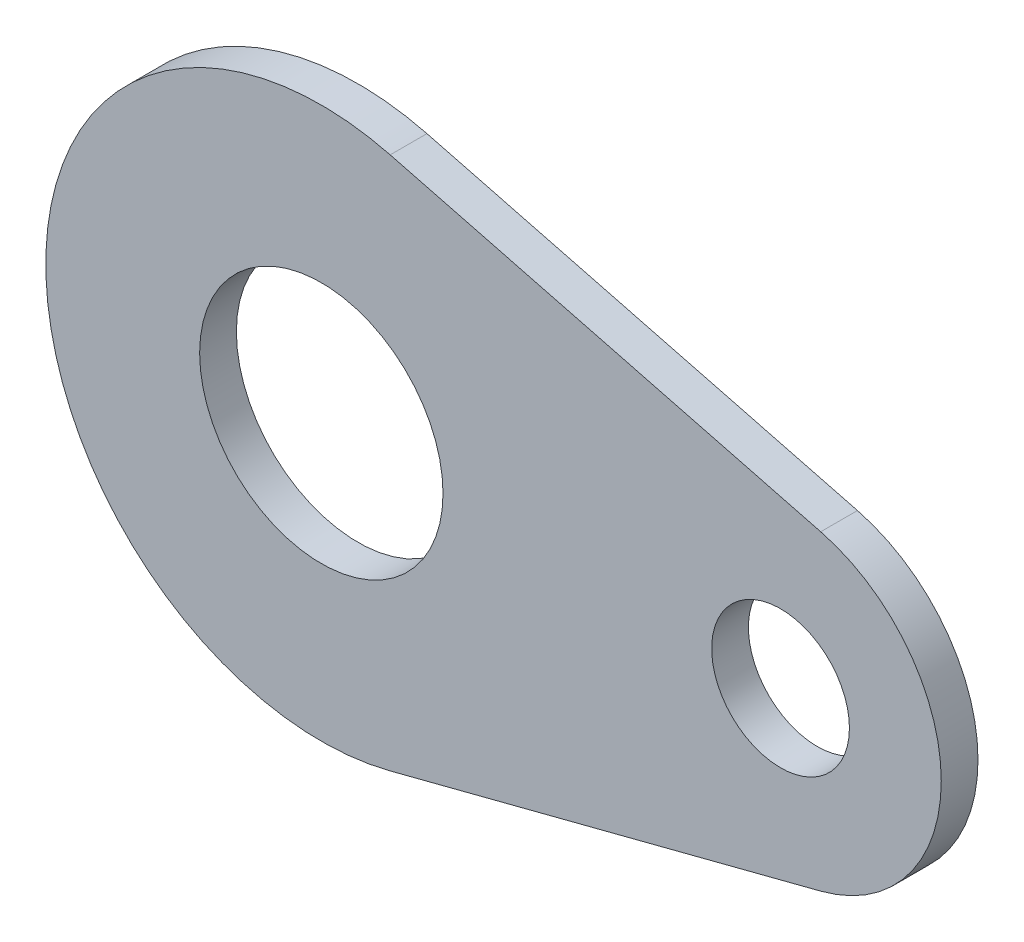
from build123d import *

# Parameters (mm, degrees)
SKETCH1_R           = 2.65
SKETCH1_R_2         = 1.5
BOSS_EXTRUDE1_DEPTH = 0.8


with BuildPart() as part:
    # Sketch1 → Boss-Extrude1 (new body)
    with BuildSketch(Plane.XY):
        with BuildLine():
            Line((1.5, 5.809475019), (10.875, 3.388860428))
            ThreePointArc((10.875, 3.388860428), (13.5, 0), (10.875, -3.388860428))
            Line((10.875, -3.388860428), (1.5, -5.809475019))
            ThreePointArc((1.5, -5.809475019), (-6, 0), (1.5, 5.809475019))
        make_face()
        Circle(SKETCH1_R, mode=Mode.SUBTRACT)
        with Locations((10, 0)):
            Circle(SKETCH1_R_2, mode=Mode.SUBTRACT)
    extrude(amount=BOSS_EXTRUDE1_DEPTH)


solid = part.part
